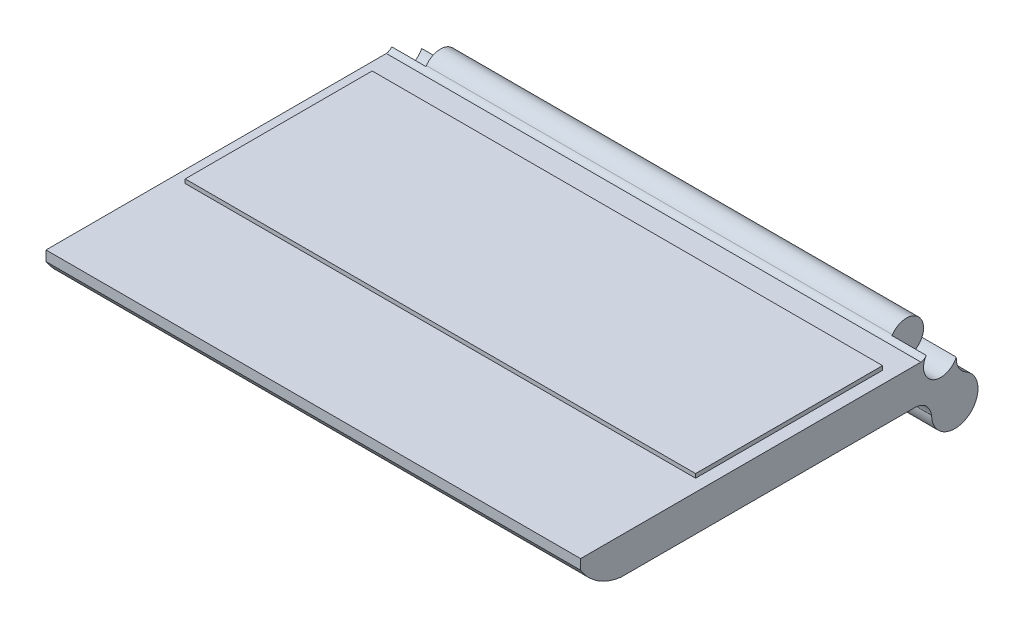
from build123d import *

# Parameters (mm, degrees)
SKETCH1_W               = 265
SKETCH1_H               = 170
BOSS_EXTRUDE1_DEPTH     = 18
CUT_EXTRUDE1_DEPTH      = 1
CUT_EXTRUDE1_DEPTH_BACK = 266
BOSS_EXTRUDE2_DEPTH     = 265
SKETCH4_W               = 253
SKETCH4_H               = 92.678428724
BOSS_EXTRUDE3_DEPTH     = 2
BOSS_EXTRUDE4_DEPTH     = 265
SKETCH8_R               = 8.5
CUT_EXTRUDE3_DEPTH      = 17


with BuildPart() as part:
    # Sketch1 → Boss-Extrude1 (new body)
    with BuildSketch(Plane(origin=(0, 0, 0), x_dir=(1, 0, 0), z_dir=(0, 1, 0))):
        Rectangle(SKETCH1_W, SKETCH1_H)
    extrude(amount=BOSS_EXTRUDE1_DEPTH)

    # Sketch2 → Cut-Extrude1 (cut, two sides)
    with BuildSketch(Plane(origin=(132.5, 0, 0), x_dir=(0, 0, -1), z_dir=(1, 0, 0))) as cut_extrude1_sk:
        with BuildLine():
            Line((-266.258489167, 313.568151134), (-85, 13))
            ThreePointArc((-85, 13), (-76.493710292, 4.201984165), (-65, 0))
            Line((-65, 0), (283.270913158, -43.625960377))
            Line((283.270913158, -43.625960377), (-99.302917842, -632.201084994))
            Line((-99.302917842, -632.201084994), (-648.832320167, -275.006973483))
            Line((-648.832320167, -275.006973483), (-266.258489167, 313.568151134))
        make_face()
    extrude(amount=CUT_EXTRUDE1_DEPTH, mode=Mode.SUBTRACT)
    extrude(cut_extrude1_sk.sketch, amount=-CUT_EXTRUDE1_DEPTH_BACK, mode=Mode.SUBTRACT)

    # Sketch3 → Boss-Extrude2 (add)
    with BuildSketch(Plane.ZY.offset(132.5)):
        with BuildLine():
            ThreePointArc((-85, 15), (-88.140347905, 8.402718027), (-95.24097163, 6.680203261))
            add(Edge.make_bspline(
                [(-95.24097163, 6.680203261), (-89.327681397, 4.618052191), (-85, 0)],
                knots=[0, 0, 0, 1, 1, 1], degree=2))
            Line((-85, 0), (-85, 15))
        make_face()
        with BuildLine():
            add(Edge.make_bspline(
                [(-86.53925872, 19.878327668), (-86.439507091, 19.716554468), (-86.33208607, 19.568480042)],
                knots=[0, 0, 0, 0.074961469, 0.074961469, 0.074961469], degree=2))
            ThreePointArc((-86.53925872, 19.878327668), (-100.596416051, 19.678768987), (-95.24097163, 6.680203261))
            ThreePointArc((-95.24097163, 6.680203261), (-88.140347905, 8.402718027), (-85, 15))
            ThreePointArc((-85, 15), (-85.339814083, 17.379362477), (-86.33208607, 19.568480042))
        make_face()
        with BuildLine():
            add(Edge.make_bspline(
                [(-86.33208607, 19.568480042), (-85.335385171, 18.194578424), (-83.678428785, 18)],
                knots=[0.074961469, 0.074961469, 0.074961469, 0.770487944, 0.770487944, 0.770487944], degree=2))
            ThreePointArc((-86.33208607, 19.568480042), (-85.339814083, 17.379362477), (-85, 15))
            Line((-85, 15), (-85, 18))
            Line((-85, 18), (-83.678428785, 18))
        make_face()
    extrude(amount=-BOSS_EXTRUDE2_DEPTH)

    # Sketch4 → Boss-Extrude3 (add)
    with BuildSketch(Plane(origin=(0, 18, 0), x_dir=(1, 0, 0), z_dir=(0, 1, 0))):
        with Locations((0, 24.339214362)):
            Rectangle(SKETCH4_W, SKETCH4_H)
    extrude(amount=BOSS_EXTRUDE3_DEPTH)

    # Sketch6 → Boss-Extrude4 (add)
    with BuildSketch(Plane.ZY.offset(132.5)):
        with BuildLine():
            Line((-101.203779097, 11.408094152), (-78.679249537, 0))
            add(Edge.make_bspline(
                [(-89, -7.5), (-87.236541116, 0.615126939), (-78.679249537, 0)],
                knots=[0, 0, 0, 1, 1, 1], degree=2))
            ThreePointArc((-89, -7.5), (-106.371084282, -17.388395692), (-106.005281627, 2.596626873))
            add(Edge.make_bspline(
                [(-106.005281627, 2.596626873), (-101.037094557, 5.737965522), (-101.203779097, 11.408094152)],
                knots=[0, 0, 0, 1, 1, 1], degree=2))
        make_face()
    extrude(amount=-BOSS_EXTRUDE4_DEPTH)

    # Sketch8 → Cut-Extrude3 (cut)
    with BuildSketch(Plane.ZY.offset(132.5)):
        with Locations((-93.5, 15)):
            Circle(SKETCH8_R)
    cut_extrude3 = extrude(amount=-CUT_EXTRUDE3_DEPTH, mode=Mode.SUBTRACT)

    # Mirror1: Cut-Extrude3 across plane
    add(cut_extrude3.mirror(Plane(origin=(0, 0, 0), x_dir=(0, 0, 1), z_dir=(1, 0, 0))), mode=Mode.SUBTRACT)


solid = part.part
